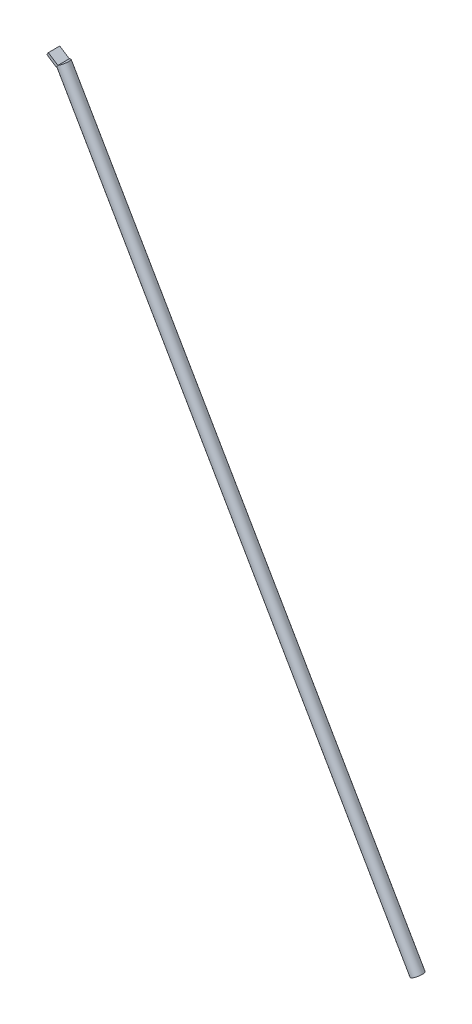
from build123d import *

# Parameters (mm, degrees)
BOSS_EXTRUDE1_DEPTH = 20
SKETCH3_R           = 10
BOSS_EXTRUDE2_DEPTH = 1240


with BuildPart() as part:
    # Sketch1 → Boss-Extrude1 (new body)
    with BuildSketch(Plane.XY):
        Polygon((0, 0), (-16.689267036, 11.021268793), (-19.444584234, 6.848952034), (-11.099950716, 1.338317638), (-2.755317198, -4.172316759), align=None)
    extrude(amount=BOSS_EXTRUDE1_DEPTH)

    # Sketch3 → Boss-Extrude2 (add)
    with BuildSketch(Plane(origin=(0, 0, 0), x_dir=(-0.8660254037844396, -0.4999999999999985, 0), z_dir=(0.4999999999999985, -0.8660254037844396, 0))):
        with Locations((0, -10)):
            Circle(SKETCH3_R)
    extrude(amount=BOSS_EXTRUDE2_DEPTH)


solid = part.part
